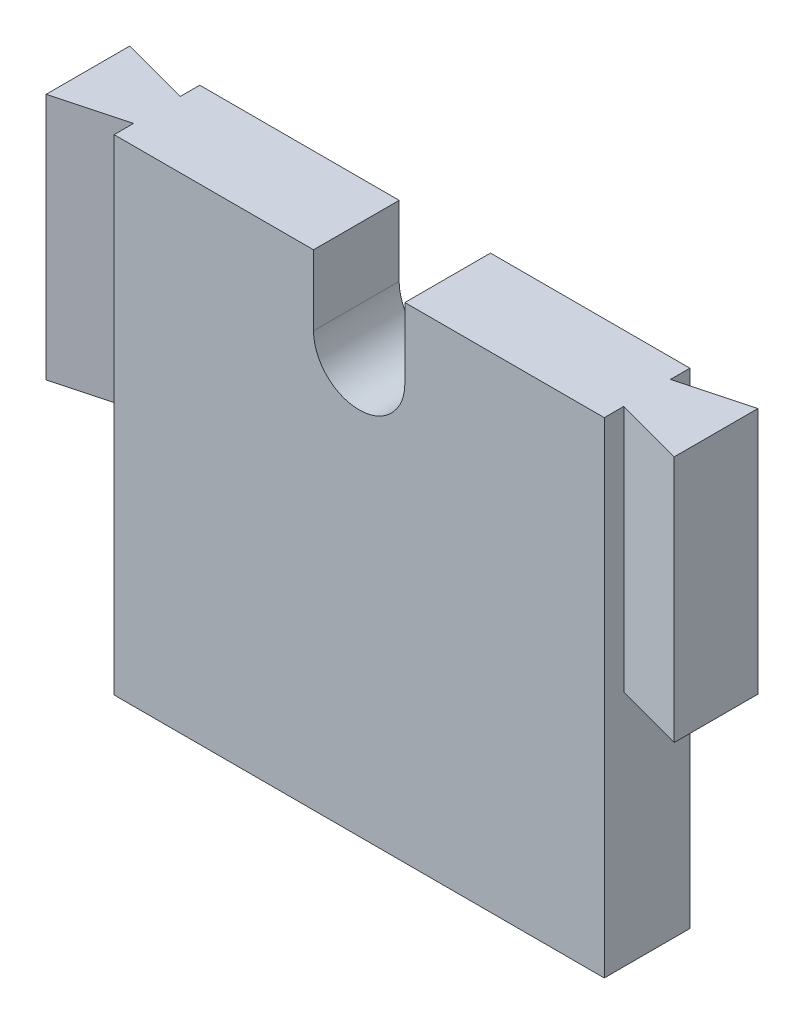
from build123d import *

# Parameters (mm, degrees)
BOSS_EXTRUDE1_DEPTH = 9
CUT_EXTRUDE1_DEPTH  = 52
SKETCH4_W           = 7.545775994
SKETCH4_H           = 9.202794467
SKETCH4_W_2         = 8.134906164
CUT_EXTRUDE2_DEPTH  = 25


with BuildPart() as part:
    # Sketch2 → Boss-Extrude1 (new body)
    with BuildSketch(Plane.XY):
        with BuildLine():
            Line((-10.152941176, 19.036764706), (-10.152941176, 26.411764706))
            Line((-10.152941176, 26.411764706), (-38.352941176, 26.411764706))
            Line((-38.352941176, 26.411764706), (-38.352941176, -24.588235294))
            Line((-38.352941176, -24.588235294), (27.647058824, -24.588235294))
            Line((27.647058824, -24.588235294), (27.647058824, 26.411764706))
            Line((27.647058824, 26.411764706), (-0.552941176, 26.411764706))
            Line((-0.552941176, 26.411764706), (-0.552941176, 19.036764706))
            ThreePointArc((-0.552941176, 19.036764706), (-5.352941176, 14.236764706), (-10.152941176, 19.036764706))
        make_face()
    extrude(amount=BOSS_EXTRUDE1_DEPTH)

    # Sketch3 → Cut-Extrude1 (cut, through all)
    with BuildSketch(Plane(origin=(0, 26.411764706, 0), x_dir=(1, 0, 0), z_dir=(0, 1, 0))):
        Polygon((28.053319282, 0), (20.402615126, -2.05), (20.402615126, 0), align=None)
        Polygon((28.053319282, -9), (20.402615126, -6.95), (20.402615126, -9), align=None)
        Polygon((-38.759201635, 0), (-31.108497479, -2.05), (-31.108497479, 0), align=None)
        Polygon((-38.759201635, -9), (-31.108497479, -6.95), (-31.108497479, -9), align=None)
    extrude(amount=-CUT_EXTRUDE1_DEPTH, mode=Mode.SUBTRACT)

    # Sketch4 → Cut-Extrude2 (cut)
    with BuildSketch(Plane.XZ.offset(24.588235294)):
        with Locations((-34.881385476, 4.601397234)):
            Rectangle(SKETCH4_W, SKETCH4_H)
        with Locations((24.470068208, 4.601397234)):
            Rectangle(SKETCH4_W_2, SKETCH4_H)
    extrude(amount=-CUT_EXTRUDE2_DEPTH, mode=Mode.SUBTRACT)


solid = part.part
